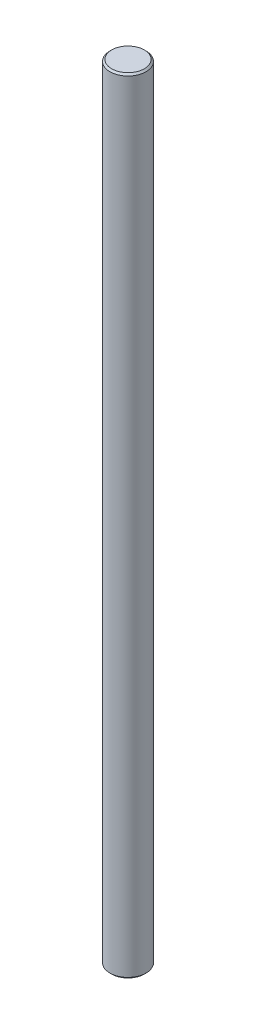
from build123d import *

# Parameters (mm, degrees)
ESQUISSE1_R        = 3.175
BOSS_EXTRU_1_DEPTH = 138
CHANFREIN1_SIZE    = 0.3


with BuildPart() as part:
    # Esquisse1 → Boss.-Extru.1 (new body)
    with BuildSketch(Plane(origin=(0, 0, 0), x_dir=(1, 0, 0), z_dir=(0, 1, 0))):
        Circle(ESQUISSE1_R)
    extrude(amount=BOSS_EXTRU_1_DEPTH)

    # Chanfrein1
    chanfrein1_edges = [part.edges().sort_by_distance(p)[0] for p in [
        (-3.175, 0, 0),
        (-3.175, 138, 0),
    ]]
    chamfer(chanfrein1_edges, length=CHANFREIN1_SIZE)


solid = part.part
